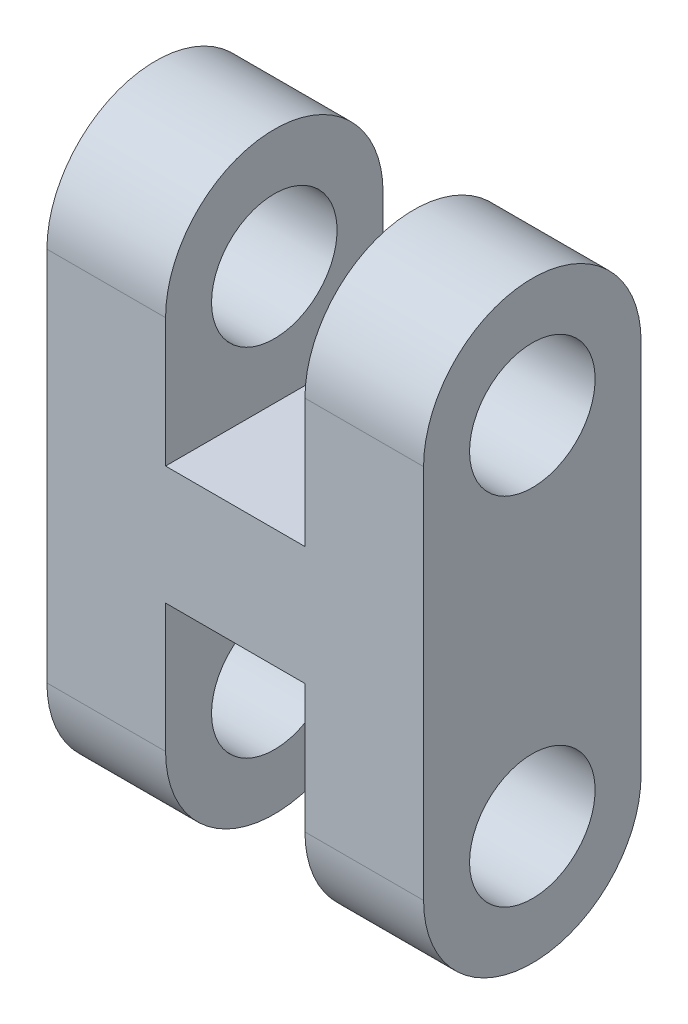
from build123d import *

# Parameters (mm, degrees)
BOSS_EXTRUDE1_DEPTH = 5.5
SKETCH3_R           = 1.5875
CUT_EXTRUDE1_DEPTH  = 9.525


with BuildPart() as part:
    # Sketch1 → Boss-Extrude1 (new body)
    with BuildSketch(Plane.XY):
        Polygon((0, 0), (-3, 0), (-3, 15), (0, 15), (0, 9), (3.525, 9), (3.525, 15), (6.525, 15), (6.525, 0), (3.525, 0), (3.525, 6), (0, 6), align=None)
    extrude(amount=BOSS_EXTRUDE1_DEPTH)

    # Sketch3 → Cut-Extrude1 (cut)
    with BuildSketch(Plane.ZY.offset(3)):
        with BuildLine():
            Line((5.5, 15), (2.75, 15))
            ThreePointArc((2.75, 15), (4.694543648, 14.194543648), (5.5, 12.25))
            Line((5.5, 12.25), (5.5, 15))
        make_face()
        with BuildLine():
            Line((0, 15), (0, 12.25))
            ThreePointArc((0, 12.25), (0.805456352, 14.194543648), (2.75, 15))
            Line((2.75, 15), (0, 15))
        make_face()
        with Locations((2.75, 12)):
            Circle(SKETCH3_R)
        with Locations((2.75, 3)):
            Circle(SKETCH3_R)
        with BuildLine():
            ThreePointArc((2.75, 0), (0.805456352, 0.805456352), (0, 2.75))
            Line((0, 2.75), (0, 0))
            Line((0, 0), (2.75, 0))
        make_face()
        with BuildLine():
            ThreePointArc((2.75, 0), (4.694543648, 0.805456352), (5.5, 2.75))
            Line((5.5, 2.75), (5.5, 0))
            Line((5.5, 0), (2.75, 0))
        make_face()
    extrude(amount=-CUT_EXTRUDE1_DEPTH, mode=Mode.SUBTRACT)


solid = part.part
